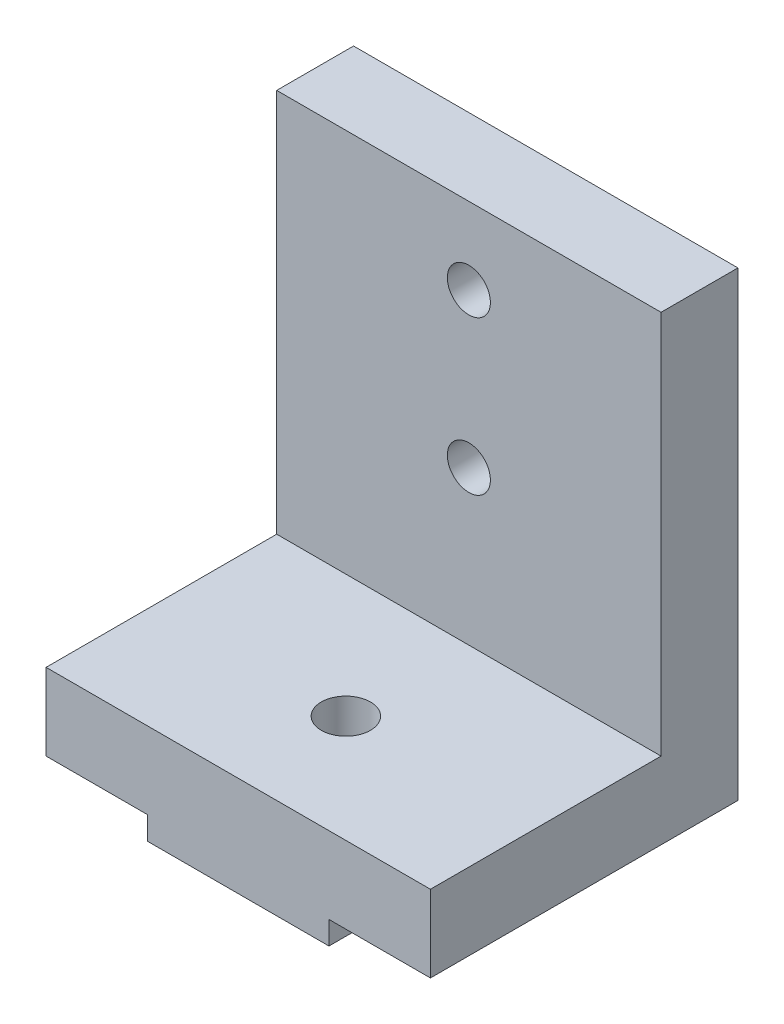
from build123d import *

# Parameters (mm, degrees)
SKETCH1_W           = 11.8
SKETCH1_H           = 1.5
BOSS_EXTRUDE1_DEPTH = 20
SKETCH3_W           = 25
SKETCH3_H           = 25
SKETCH3_R           = 1.4
BOSS_EXTRUDE2_DEPTH = 5
SKETCH4_R           = 1.6
CUT_EXTRUDE2_DEPTH  = 7.5


with BuildPart() as part:
    # Sketch1 → Boss-Extrude1 (new body)
    with BuildSketch(Plane.XY):
        Polygon((-6.6, 1.5), (0, 1.5), (11.8, 1.5), (18.4, 1.5), (18.4, 6.5), (-6.6, 6.5), align=None)
        with Locations((5.9, 0.75)):
            Rectangle(SKETCH1_W, SKETCH1_H)
    extrude(amount=BOSS_EXTRUDE1_DEPTH)

    # Sketch3 → Boss-Extrude2 (add)
    with BuildSketch(Plane(origin=(0, 0, 0), x_dir=(-1, 0, 0), z_dir=(0, 0, -1))):
        with Locations((-5.9, 19)):
            Rectangle(SKETCH3_W, SKETCH3_H)
        with Locations((-5.9, 16.5)):
            Circle(SKETCH3_R, mode=Mode.SUBTRACT)
        with Locations((-5.9, 26.5)):
            Circle(SKETCH3_R, mode=Mode.SUBTRACT)
    extrude(amount=-BOSS_EXTRUDE2_DEPTH)

    # Sketch4 → Cut-Extrude2 (cut, through all)
    with BuildSketch(Plane(origin=(0, 6.5, 0), x_dir=(1, 0, 0), z_dir=(0, 1, 0))):
        with Locations((5.9, -13)):
            Circle(SKETCH4_R)
    extrude(amount=-CUT_EXTRUDE2_DEPTH, mode=Mode.SUBTRACT)


solid = part.part
